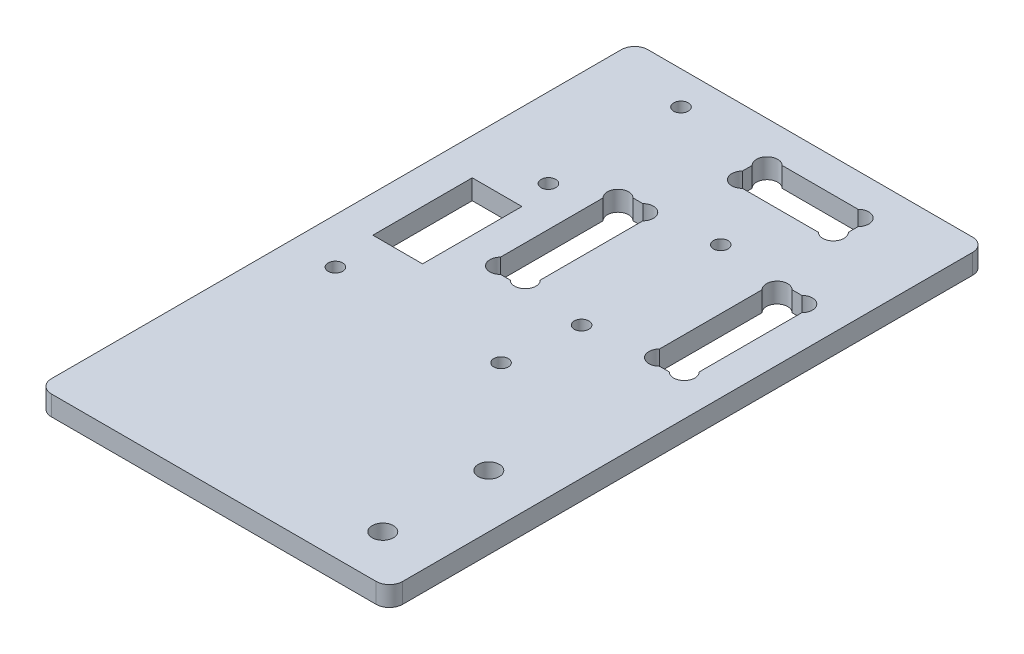
from build123d import *

# Parameters (mm, degrees)
EXTRUSION1_DEPTH        = 3
ESQUISSE2_R             = 1.6
ENL_V_MAT_EXTRU_1_DEPTH = 4
ESQUISSE4_R             = 1.1
ESQUISSE4_W             = 7.5
ESQUISSE4_H             = 15
ENL_V_MAT_EXTRU_2_DEPTH = 4
ESQUISSE5_R             = 1.1
ENL_V_MAT_EXTRU_3_DEPTH = 4


with BuildPart() as part:
    # Esquisse1 → Extrusion1 (new body)
    with BuildSketch(Plane(origin=(0, 0, 0), x_dir=(1, 0, 0), z_dir=(0, 1, 0))):
        with BuildLine():
            Line((0, 88), (0, 2))
            ThreePointArc((0, 2), (0.585786438, 0.585786438), (2, 0))
            Line((2, 0), (51, 0))
            ThreePointArc((51, 0), (52.414213562, 0.585786438), (53, 2))
            Line((53, 2), (53, 88))
            ThreePointArc((53, 88), (52.414213562, 89.414213562), (51, 90))
            Line((51, 90), (2, 90))
            ThreePointArc((2, 90), (0.585786438, 89.414213562), (0, 88))
        make_face()
    extrude(amount=EXTRUSION1_DEPTH)

    # Esquisse2 → Enlèv. mat.-Extru.1 (cut, through all)
    with BuildSketch(Plane.XZ):
        with Locations(Location((45, -23, 0), (0, 0, 270))):  # turned: the seam where the file's is
            Circle(ESQUISSE2_R)
        with Locations(Location((45, -7, 0), (0, 0, 270))):  # turned: the seam where the file's is
            Circle(ESQUISSE2_R)
        with BuildLine():
            Line((41, -82.7372583), (41, -81.2627417))
            ThreePointArc((41, -81.2627417), (41, -79), (38.7372583, -79))
            Line((38.7372583, -79), (27.2627417, -79))
            ThreePointArc((27.2627417, -79), (25, -79), (25, -81.2627417))
            Line((25, -81.2627417), (25, -82.7372583))
            ThreePointArc((25, -82.7372583), (25, -85), (27.2627417, -85))
            Line((27.2627417, -85), (38.7372583, -85))
            ThreePointArc((38.7372583, -85), (41, -85), (41, -82.7372583))
        make_face()
        with BuildLine():
            Line((45.7372583, -49.5), (44.2627417, -49.5))
            ThreePointArc((44.2627417, -49.5), (42, -49.5), (42, -51.7627417))
            Line((42, -51.7627417), (42, -67.2372583))
            ThreePointArc((42, -67.2372583), (42, -69.5), (44.2627417, -69.5))
            Line((44.2627417, -69.5), (45.7372583, -69.5))
            ThreePointArc((45.7372583, -69.5), (48, -69.5), (48, -67.2372583))
            Line((48, -67.2372583), (48, -51.7627417))
            ThreePointArc((48, -51.7627417), (48, -49.5), (45.7372583, -49.5))
        make_face()
        with BuildLine():
            Line((24, -67.2372583), (24, -51.7627417))
            ThreePointArc((24, -51.7627417), (24, -49.5), (21.7372583, -49.5))
            Line((21.7372583, -49.5), (20.2627417, -49.5))
            ThreePointArc((20.2627417, -49.5), (18, -49.5), (18, -51.7627417))
            Line((18, -51.7627417), (18, -67.2372583))
            ThreePointArc((18, -67.2372583), (18, -69.5), (20.2627417, -69.5))
            Line((20.2627417, -69.5), (21.7372583, -69.5))
            ThreePointArc((21.7372583, -69.5), (24, -69.5), (24, -67.2372583))
        make_face()
    extrude(amount=-ENL_V_MAT_EXTRU_1_DEPTH, mode=Mode.SUBTRACT)

    # Esquisse4 → Enlèv. mat.-Extru.2 (cut, through all)
    with BuildSketch(Plane(origin=(0, 3, 0), x_dir=(1, 0, 0), z_dir=(0, 1, 0))):
        with Locations(Location((12, 85, 0), (0, 0, 270))):  # turned: the seam where the file's is
            Circle(ESQUISSE4_R)
        with Locations(Location((12, 65, 0), (0, 0, 270))):  # turned: the seam where the file's is
            Circle(ESQUISSE4_R)
        with Locations(Location((33, 70, 0), (0, 0, 270))):  # turned: the seam where the file's is
            Circle(ESQUISSE4_R)
        with Locations(Location((33, 49, 0), (0, 0, 270))):  # turned: the seam where the file's is
            Circle(ESQUISSE4_R)
        with Locations((9.25, 52.5)):
            Rectangle(ESQUISSE4_W, ESQUISSE4_H)
    extrude(amount=-ENL_V_MAT_EXTRU_2_DEPTH, mode=Mode.SUBTRACT)

    # Esquisse5 → Enlèv. mat.-Extru.3 (cut, through all)
    with BuildSketch(Plane(origin=(0, 3, 0), x_dir=(1, 0, 0), z_dir=(0, 1, 0))):
        with Locations(Location((6.847371534, 38, 0), (0, 0, 270))):  # turned: the seam where the file's is
            Circle(ESQUISSE5_R)
        with Locations(Location((31.847371534, 38, 0), (0, 0, 270))):  # turned: the seam where the file's is
            Circle(ESQUISSE5_R)
    extrude(amount=-ENL_V_MAT_EXTRU_3_DEPTH, mode=Mode.SUBTRACT)


solid = part.part
